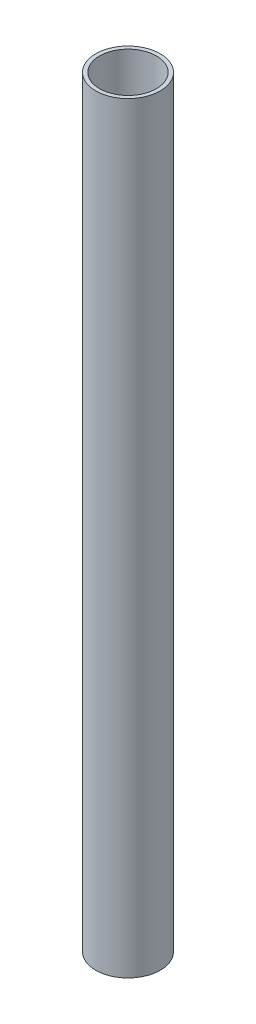
from build123d import *

# Parameters (mm, degrees)
SKETCH1_R           = 42.3
BOSS_EXTRUDE1_DEPTH = 1000
SHELL1_T            = -5


with BuildPart() as part:
    # Sketch1 → Boss-Extrude1 (new body)
    with BuildSketch(Plane(origin=(0, 0, 0), x_dir=(1, 0, 0), z_dir=(0, 1, 0))):
        with Locations(Location((0, 0, 0), (0, 0, 270))):
            Circle(SKETCH1_R)
    extrude(amount=BOSS_EXTRUDE1_DEPTH)

    # Shell1
    shell1_openings = [part.faces().sort_by_distance(p)[0] for p in [
        (0, 1000, 0),
    ]]
    offset(amount=SHELL1_T, openings=shell1_openings, kind=Kind.INTERSECTION)


solid = part.part
